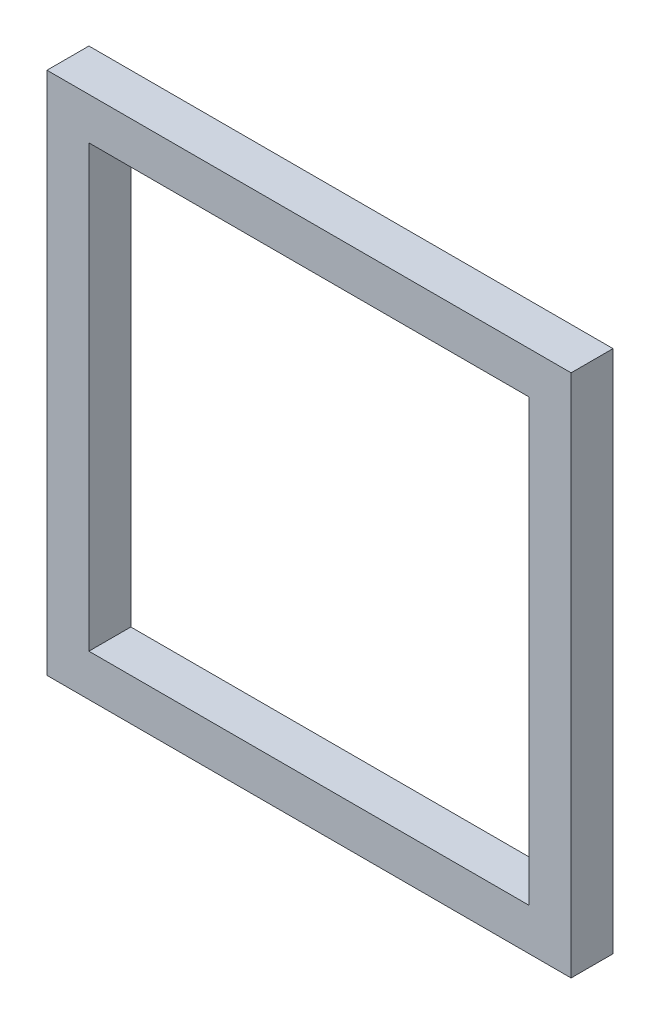
from build123d import *

# Parameters (mm, degrees)
SKETCH1_W           = 50
SKETCH1_H           = 50
SKETCH1_W_2         = 42
SKETCH1_H_2         = 42
BOSS_EXTRUDE1_DEPTH = 4


with BuildPart() as part:
    # Sketch1 → Boss-Extrude1 (new body)
    with BuildSketch(Plane.XY):
        with Locations((1.294117647, -10.514705882)):
            Rectangle(SKETCH1_W, SKETCH1_H)
        with Locations((1.294117647, -10.514705882)):
            Rectangle(SKETCH1_W_2, SKETCH1_H_2, mode=Mode.SUBTRACT)
    extrude(amount=BOSS_EXTRUDE1_DEPTH)


solid = part.part
